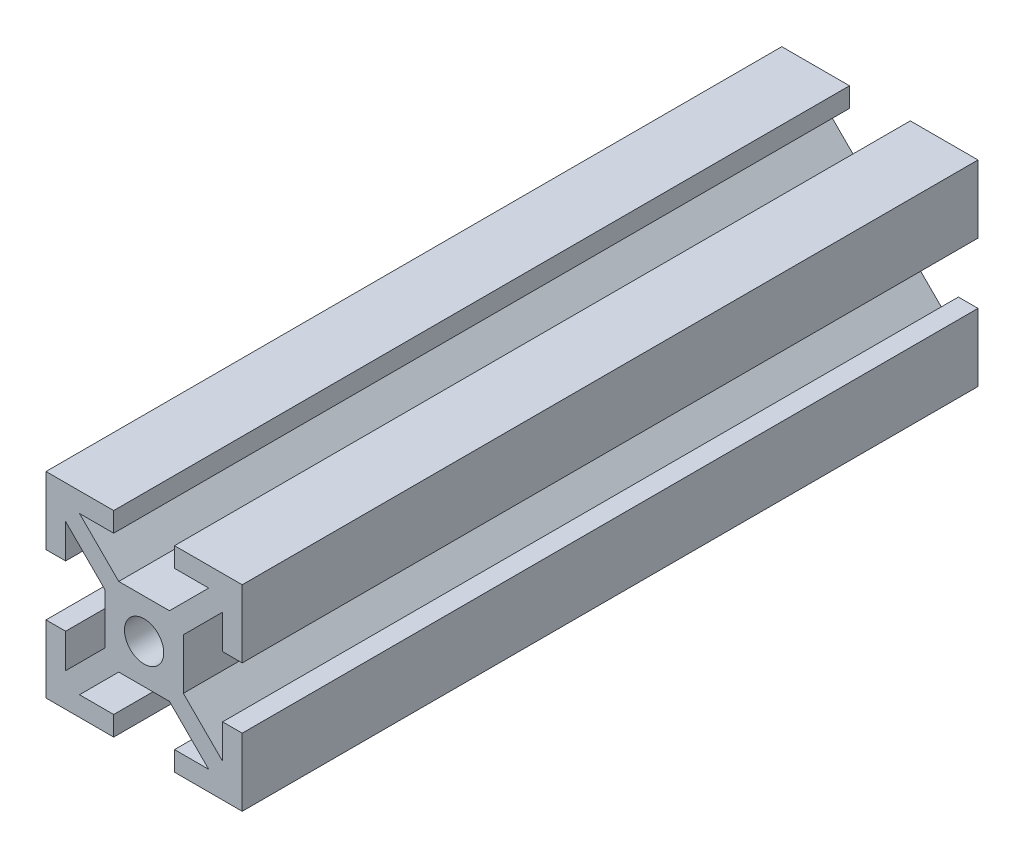
from build123d import *

# Parameters (mm, degrees)
SKETCH1_R           = 2
BOSS_EXTRUDE1_DEPTH = 75


with BuildPart() as part:
    # Sketch1 → Boss-Extrude1 (new body)
    with BuildSketch(Plane.XY):
        Polygon((-3.1, 10), (-10, 10), (-10, 3.1), (-8, 3.1), (-8, 6.585786438), (-4, 2.585786438), (-4, -2.585786438), (-8, -6.585786438), (-8, -3.1), (-10, -3.1), (-10, -10), (-3.1, -10), (-3.1, -8), (-6.585786438, -8), (-2.585786438, -4), (2.585786438, -4), (6.585786438, -8), (3.1, -8), (3.1, -10), (10, -10), (10, -3.1), (8, -3.1), (8, -6.585786438), (4, -2.585786438), (4, 2.585786438), (8, 6.585786438), (8, 3.1), (10, 3.1), (10, 10), (3.1, 10), (3.1, 8), (6.585786438, 8), (2.585786438, 4), (-2.585786438, 4), (-6.585786438, 8), (-3.1, 8), align=None)
        Circle(SKETCH1_R, mode=Mode.SUBTRACT)
    extrude(amount=BOSS_EXTRUDE1_DEPTH)


solid = part.part
